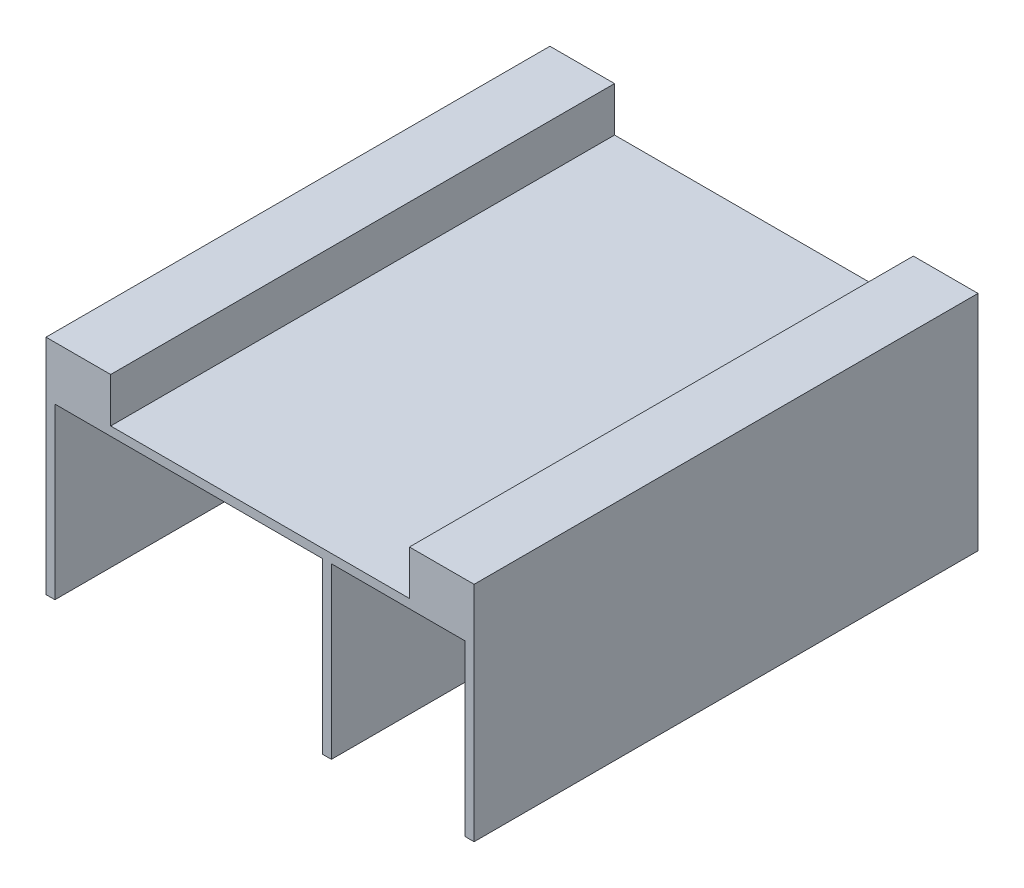
from build123d import *

# Parameters (mm, degrees)
SKETCH_1_W          = 96
SKETCH_1_H          = 113
EXTRUDE_1_DEPTH     = 50
SKETCH_2_W          = 67
SKETCH_2_H          = 113
CUT_EXTRUDE_1_DEPTH = 10
SKETCH_3_W          = 60
SKETCH_3_H          = 113
SKETCH_3_W_2        = 30
CUT_EXTRUDE_2_DEPTH = 38
SKETCH_4_W          = 80
SKETCH_4_H          = 15
CUT_EXTRUDE_3_DEPTH = 2


with BuildPart() as part:
    # Эскиз1 → Бобышка-Вытянуть1 (new body)
    with BuildSketch(Plane(origin=(0, 0, 0), x_dir=(1, 0, 0), z_dir=(0, 1, 0))):
        with Locations((48, 56.5)):
            Rectangle(SKETCH_1_W, SKETCH_1_H)
    extrude(amount=EXTRUDE_1_DEPTH)

    # Эскиз2 → Вырез-Вытянуть1 (cut)
    with BuildSketch(Plane(origin=(0, 50, 0), x_dir=(1, 0, 0), z_dir=(0, 1, 0))):
        with Locations((48, 56.5)):
            Rectangle(SKETCH_2_W, SKETCH_2_H)
    extrude(amount=-CUT_EXTRUDE_1_DEPTH, mode=Mode.SUBTRACT)

    # Эскиз3 → Вырез-Вытянуть2 (cut)
    with BuildSketch(Plane.XZ):
        with Locations((32, -56.5)):
            Rectangle(SKETCH_3_W, SKETCH_3_H)
        with Locations((79, -56.5)):
            Rectangle(SKETCH_3_W_2, SKETCH_3_H)
    extrude(amount=-CUT_EXTRUDE_2_DEPTH, mode=Mode.SUBTRACT)

    # Эскиз4 → Вырез-Вытянуть3 (cut)
    with BuildSketch(Plane.ZY):
        with Locations((-66, 28.5)):
            Rectangle(SKETCH_4_W, SKETCH_4_H)
    extrude(amount=-CUT_EXTRUDE_3_DEPTH, mode=Mode.SUBTRACT)


solid = part.part
